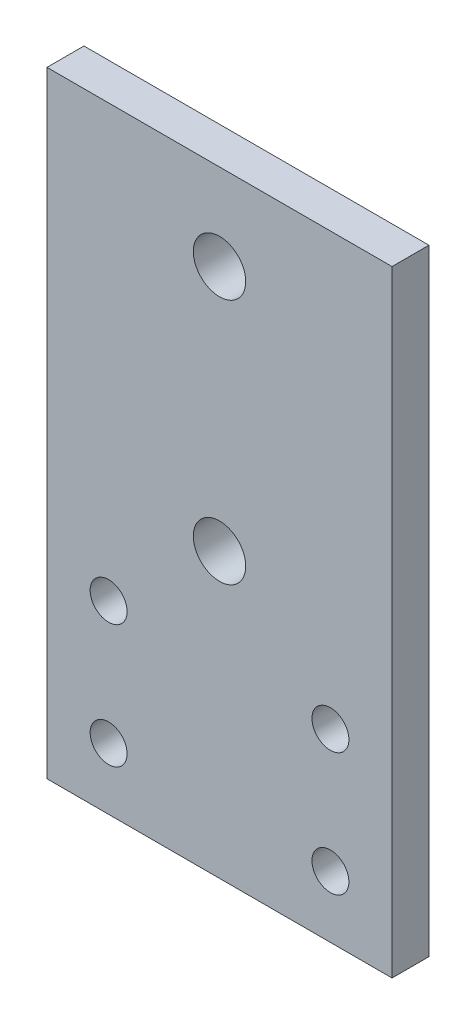
from build123d import *

# Parameters (mm, degrees)
ESBO_O1_W                = 28
ESBO_O1_H                = 50
ESBO_O1_R                = 2.125
ESBO_O1_R_2              = 1.5
RESSALTO_EXTRUS_O1_DEPTH = 3


with BuildPart() as part:
    # Esboço1 → Ressalto-extrusão1 (new body)
    with BuildSketch(Plane.XY):
        Rectangle(ESBO_O1_W, ESBO_O1_H)
        with Locations((0, 18)):
            Circle(ESBO_O1_R, mode=Mode.SUBTRACT)
        with Locations((0, -2)):
            Circle(ESBO_O1_R, mode=Mode.SUBTRACT)
        with Locations((-9, -10)):
            Circle(ESBO_O1_R_2, mode=Mode.SUBTRACT)
        with Locations((-9, -20)):
            Circle(ESBO_O1_R_2, mode=Mode.SUBTRACT)
        with Locations((9, -20)):
            Circle(ESBO_O1_R_2, mode=Mode.SUBTRACT)
        with Locations((9, -10)):
            Circle(ESBO_O1_R_2, mode=Mode.SUBTRACT)
    extrude(amount=RESSALTO_EXTRUS_O1_DEPTH)


solid = part.part
